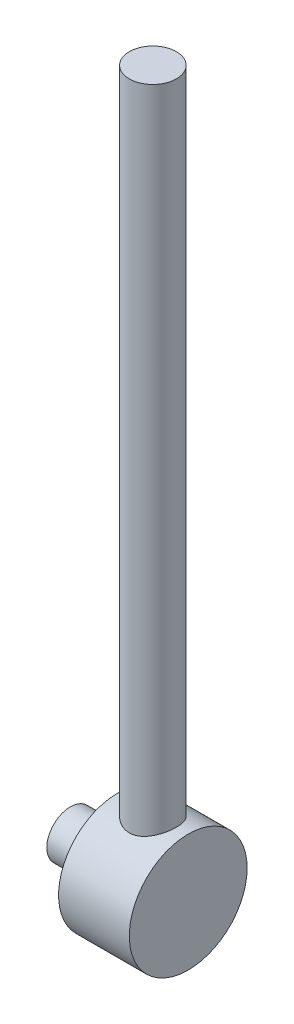
from build123d import *

# Parameters (mm, degrees)
SKETCH_1_R           = 12.5
EXTRUDE_1_DEPTH      = 15
SKETCH_1_3_R         = 5
EXTRUDE_2_DEPTH      = 10
EXTRUDE_3_REACH      = 165.669
EXTRUDE_3_END_RADIUS = 12.5
SKETCH_2_R           = 5


with BuildPart() as part:
    # 草图1 → 凸台-拉伸1 (new body)
    with BuildSketch(Plane(origin=(0, 0, 0), x_dir=(0, 0, -1), z_dir=(1, 0, 0))):
        Circle(SKETCH_1_R)
    extrude(amount=EXTRUDE_1_DEPTH)

    # 草图1<3> → 凸台-拉伸2 (add)
    with BuildSketch(Plane(origin=(0, 0, 0), x_dir=(0, 0, -1), z_dir=(1, 0, 0))):
        Circle(SKETCH_1_3_R)
    extrude(amount=-EXTRUDE_2_DEPTH)

    # 凸台-拉伸3: up to this cylinder (the profile starts outside it)
    extrude_3_end = Plane(origin=(7.5, 0, 0), z_dir=(-1, 0, 0)) * Cylinder(EXTRUDE_3_END_RADIUS, 357.338, mode=Mode.PRIVATE)
    # 草图2 → 凸台-拉伸3 (add, up to the surface)
    with BuildSketch(Plane(origin=(0, 150, 0), x_dir=(1, 0, 0), z_dir=(0, 1, 0)), mode=Mode.PRIVATE) as extrude_3_sk1:
        with Locations((7.5, 0)):
            Circle(SKETCH_2_R)
    extrude_3_tool1 = extrude(extrude_3_sk1.sketch, amount=-EXTRUDE_3_REACH, mode=Mode.PRIVATE) - extrude_3_end
    add(extrude_3_tool1.solids().sort_by_distance((7.5, 150, 0))[0])


solid = part.part
